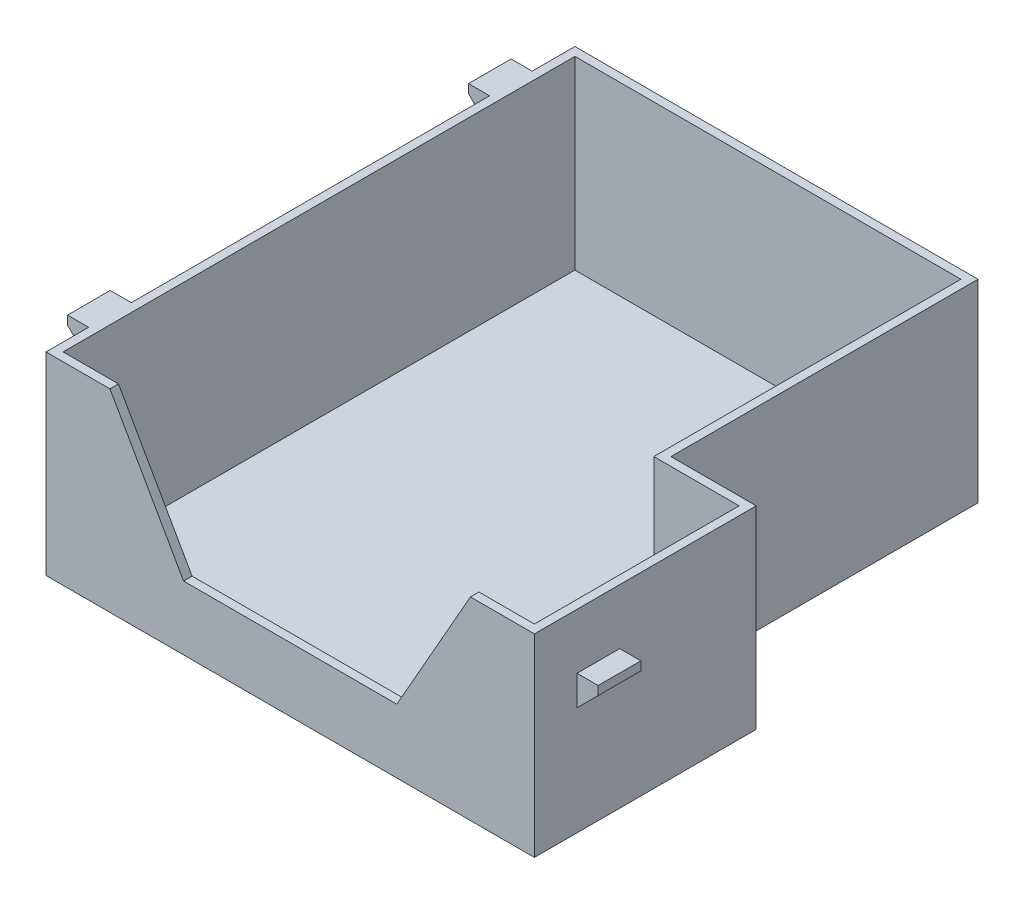
from build123d import *

# Parameters (mm, degrees)
RESSALTO_EXTRUS_O1_DEPTH  = 2
ESBO_O2_W                 = 94.5
ESBO_O2_H                 = 45.4
RESSALTO_EXTRUS_O2_DEPTH  = 2
RESSALTO_EXTRUS_O3_DEPTH  = 2
ESBO_O4_W                 = 124
ESBO_O4_H                 = 45.4
RESSALTO_EXTRUS_O4_DEPTH  = 2
ESBO_O5_W                 = 50
ESBO_O5_H                 = 45.4
RESSALTO_EXTRUS_O5_DEPTH  = 2
RESSALTO_EXTRUS_O6_START  = -10
RESSALTO_EXTRUS_O6_DEPTH  = 10
RESSALTO_EXTRUS_O7_START  = -10
RESSALTO_EXTRUS_O7_DEPTH  = 10
RESSALTO_EXTRUS_O8_START  = -10
RESSALTO_EXTRUS_O8_DEPTH  = 10
ESBO_O11_W                = 22
ESBO_O11_H                = 45.4
RESSALTO_EXTRUS_O9_DEPTH  = 2
ESBO_O14_W                = 72
ESBO_O14_H                = 45.4
RESSALTO_EXTRUS_O14_DEPTH = 2


with BuildPart() as part:
    # Esboço1 → Ressalto-extrusão1 (new body)
    with BuildSketch(Plane(origin=(0, 0, 0), x_dir=(1, 0, 0), z_dir=(0, 1, 0))):
        Polygon((57.25, -12), (37.25, -12), (37.25, 62), (-57.25, 62), (-57.25, -62), (57.25, -62), align=None)
    extrude(amount=RESSALTO_EXTRUS_O1_DEPTH)

    # Esboço2 → Ressalto-extrusão2 (add)
    with BuildSketch(Plane(origin=(0, 0, -62), x_dir=(-1, 0, 0), z_dir=(0, 0, -1))):
        with Locations((10, 22.7)):
            Rectangle(ESBO_O2_W, ESBO_O2_H)
    extrude(amount=-RESSALTO_EXTRUS_O2_DEPTH)

    # Esboço3 → Ressalto-extrusão3 (add)
    with BuildSketch(Plane.XY.offset(62)):
        Polygon((-57.25, 0), (-57.25, 45.4), (-42.25, 45.4), (-25, 15), (25, 15), (42.25, 45.4), (57.25, 45.4), (57.25, 0), align=None)
    extrude(amount=-RESSALTO_EXTRUS_O3_DEPTH)

    # Esboço4 → Ressalto-extrusão4 (add)
    with BuildSketch(Plane.ZY.offset(57.25)):
        with Locations((0, 22.7)):
            Rectangle(ESBO_O4_W, ESBO_O4_H)
    extrude(amount=-RESSALTO_EXTRUS_O4_DEPTH)

    # Esboço5 → Ressalto-extrusão5 (add)
    with BuildSketch(Plane(origin=(57.25, 0, 0), x_dir=(0, 0, -1), z_dir=(1, 0, 0))):
        with Locations((-37, 22.7)):
            Rectangle(ESBO_O5_W, ESBO_O5_H)
    extrude(amount=-RESSALTO_EXTRUS_O5_DEPTH)

    # Esboço6 → Ressalto-extrusão6 (add)
    with BuildSketch(Plane.XY.offset(62).offset(RESSALTO_EXTRUS_O6_START)):
        Polygon((57.25, 25.4), (62.199747468, 30.349747468), (62.199747468, 32.4), (57.25, 32.4), align=None)
    extrude(amount=-RESSALTO_EXTRUS_O6_DEPTH)

    # Esboço8 → Ressalto-extrusão7 (add)
    with BuildSketch(Plane.XY.offset(62).offset(RESSALTO_EXTRUS_O7_START)):
        Polygon((-57.25, 38.4), (-62.199747468, 43.349747468), (-62.199747468, 45.4), (-57.25, 45.4), align=None)
    extrude(amount=-RESSALTO_EXTRUS_O7_DEPTH)

    # Esboço10 → Ressalto-extrusão8 (add)
    with BuildSketch(Plane(origin=(0, 0, -62), x_dir=(-1, 0, 0), z_dir=(0, 0, -1)).offset(RESSALTO_EXTRUS_O8_START)):
        Polygon((57.25, 45.4), (57.25, 38.4), (62.199747468, 43.349747468), (62.199747468, 45.4), align=None)
    extrude(amount=-RESSALTO_EXTRUS_O8_DEPTH)

    # Esboço11 → Ressalto-extrusão9 (add)
    with BuildSketch(Plane(origin=(0, 0, 12), x_dir=(-1, 0, 0), z_dir=(0, 0, -1))):
        with Locations((-46.25, 22.7)):
            Rectangle(ESBO_O11_W, ESBO_O11_H)
    extrude(amount=RESSALTO_EXTRUS_O9_DEPTH)

    # Esboço14 → Ressalto-extrusão14 (add)
    with BuildSketch(Plane(origin=(37.25, 0, 0), x_dir=(0, 0, -1), z_dir=(1, 0, 0))):
        with Locations((26, 22.7)):
            Rectangle(ESBO_O14_W, ESBO_O14_H)
    extrude(amount=-RESSALTO_EXTRUS_O14_DEPTH)


solid = part.part
